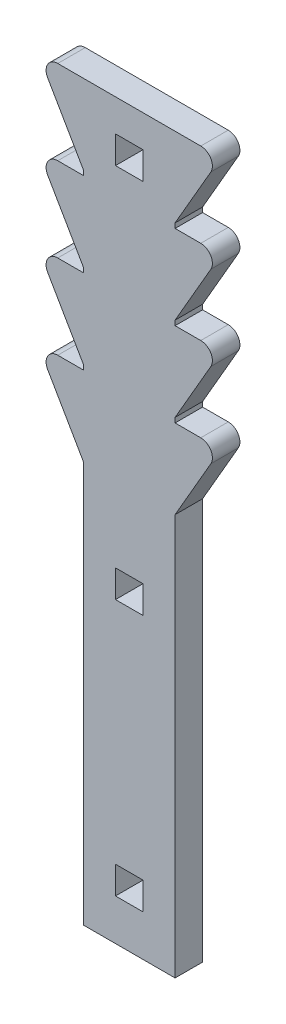
from build123d import *

# Parameters (mm, degrees)
SKETCH2_W           = 15
SKETCH2_H           = 15
BOSS_EXTRUDE1_DEPTH = 15
FILLET1_R           = 6.35


with BuildPart() as part:
    # Sketch2 → Boss-Extrude1 (new body)
    with BuildSketch(Plane.XY):
        Polygon((75, 0), (75, -200), (25, -200), (25, 0), (25, 18.884295249), (0, 62.185565438), (25, 62.185565438), (25, 64.822440103), (0, 108.123710292), (25, 108.123710292), (25, 110.760584957), (0, 154.061855146), (25, 154.061855146), (25, 156.698729811), (0, 200), (100, 200), (75, 156.698729811), (75, 154.061855146), (100, 154.061855146), (75, 110.760584957), (75, 108.123710292), (100, 108.123710292), (75, 64.822440103), (75, 62.185565438), (100, 62.185565438), (75, 18.884295249), align=None)
        with Locations((50, -170)):
            Rectangle(SKETCH2_W, SKETCH2_H, mode=Mode.SUBTRACT)
        with Locations((50, -30)):
            Rectangle(SKETCH2_W, SKETCH2_H, mode=Mode.SUBTRACT)
        with Locations((50, 175)):
            Rectangle(SKETCH2_W, SKETCH2_H, mode=Mode.SUBTRACT)
    extrude(amount=-BOSS_EXTRUDE1_DEPTH)

    # Fillet1
    fillet1_edges = [part.edges().sort_by_distance(p)[0] for p in [
        (0, 62.185565438, -7.5),
        (0, 108.123710292, -7.5),
        (0, 154.061855146, -7.5),
        (0, 200, -7.5),
        (100, 200, -7.5),
        (100, 154.061855146, -7.5),
        (100, 108.123710292, -7.5),
        (100, 62.185565438, -7.5),
    ]]
    fillet(fillet1_edges, radius=FILLET1_R)


solid = part.part
